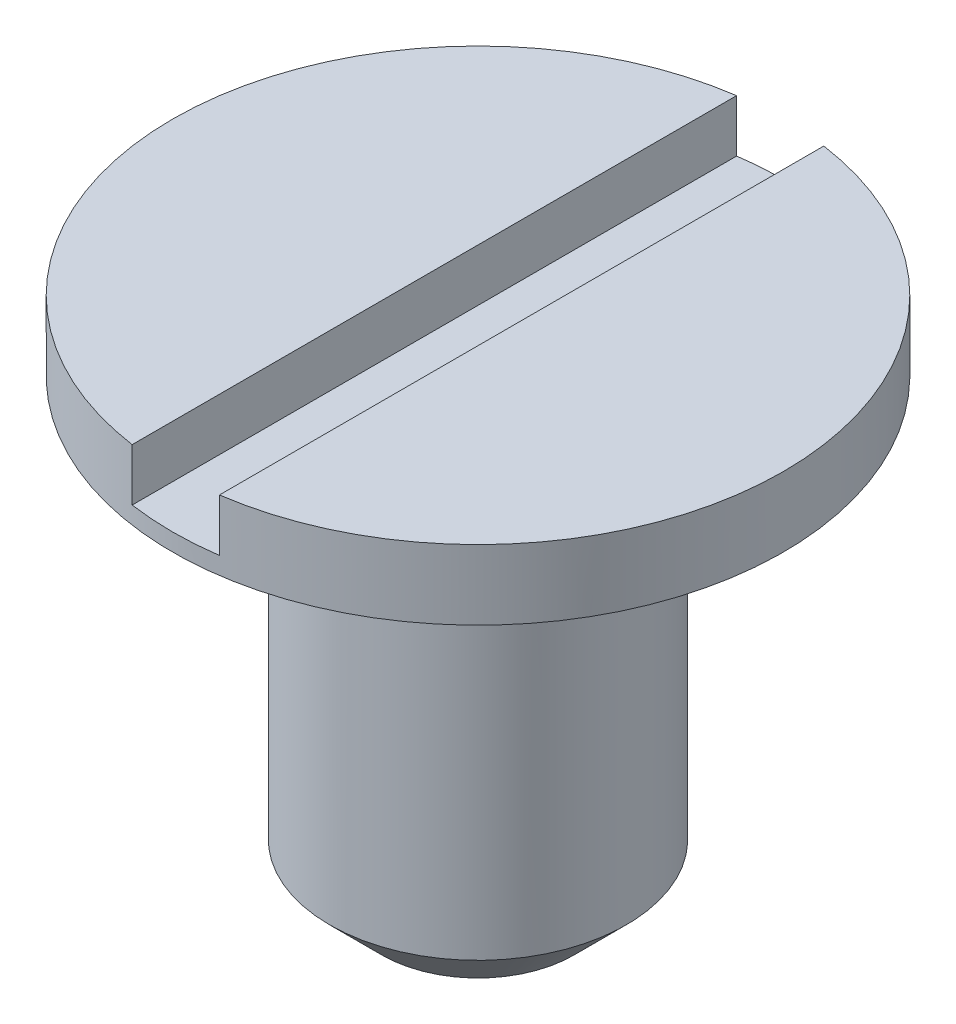
from build123d import *

# Parameters (mm, degrees)
SKETCH1_R           = 1.75
BOSS_EXTRUDE1_DEPTH = 3
SKETCH2_W           = 0.9
SKETCH2_H           = 2.6
SKETCH3_W           = 0.5
SKETCH3_H           = 3.7
CUT_EXTRUDE1_DEPTH  = 0.3
CHAMFER1_SIZE       = 0.3


with BuildPart() as part:
    # Sketch1 → Boss-Extrude1 (new body)
    with BuildSketch(Plane(origin=(0, 0, 0), x_dir=(1, 0, 0), z_dir=(0, 1, 0))):
        Circle(SKETCH1_R)
    extrude(amount=BOSS_EXTRUDE1_DEPTH)

    # Sketch2 → Cut-Revolve1 (revolve, cut)
    with BuildSketch(Plane.XY):
        with Locations((1.3, 1.3)):
            Rectangle(SKETCH2_W, SKETCH2_H)
    revolve(axis=Axis((0, 0, 0), (0, 1, 0)), mode=Mode.SUBTRACT)

    # Sketch3 → Cut-Extrude1 (cut)
    with BuildSketch(Plane(origin=(0, 3, 0), x_dir=(1, 0, 0), z_dir=(0, 1, 0))):
        Rectangle(SKETCH3_W, SKETCH3_H)
    extrude(amount=-CUT_EXTRUDE1_DEPTH, mode=Mode.SUBTRACT)

    # Chamfer1
    chamfer1_edges = [part.edges().sort_by_distance(p)[0] for p in [
        (-0.85, 0, 0),
    ]]
    chamfer(chamfer1_edges, length=CHAMFER1_SIZE)


solid = part.part
